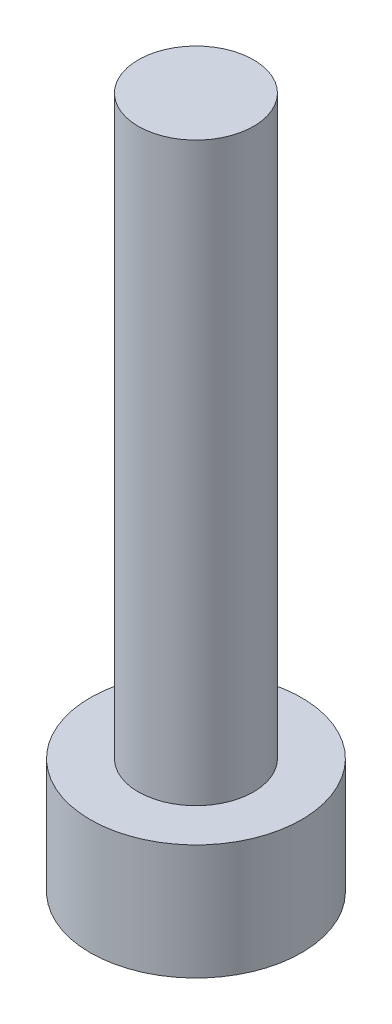
from build123d import *

# Parameters (mm, degrees)
SKETCH1_R           = 2.75
BOSS_EXTRUDE1_DEPTH = 3
SKETCH2_R           = 1.5
BOSS_EXTRUDE2_DEPTH = 15
CUT_EXTRUDE1_DEPTH  = 1.5


with BuildPart() as part:
    # Sketch1 → Boss-Extrude1 (new body)
    with BuildSketch(Plane(origin=(0, 0, 0), x_dir=(1, 0, 0), z_dir=(0, 1, 0))):
        Circle(SKETCH1_R)
    extrude(amount=BOSS_EXTRUDE1_DEPTH)

    # Sketch2 → Boss-Extrude2 (add)
    with BuildSketch(Plane(origin=(0, 3, 0), x_dir=(1, 0, 0), z_dir=(0, 1, 0))):
        Circle(SKETCH2_R)
    extrude(amount=BOSS_EXTRUDE2_DEPTH)

    # Sketch3 → Cut-Extrude1 (cut)
    with BuildSketch(Plane(origin=(0, 0, 0), x_dir=(-1, 0, 0), z_dir=(0, -1, 0))):
        Polygon((0, -1.443375673), (1.25, -0.721687836), (1.25, 0.721687836), (0, 1.443375673), (-1.25, 0.721687836), (-1.25, -0.721687836), align=None)
    extrude(amount=-CUT_EXTRUDE1_DEPTH, mode=Mode.SUBTRACT)


solid = part.part
